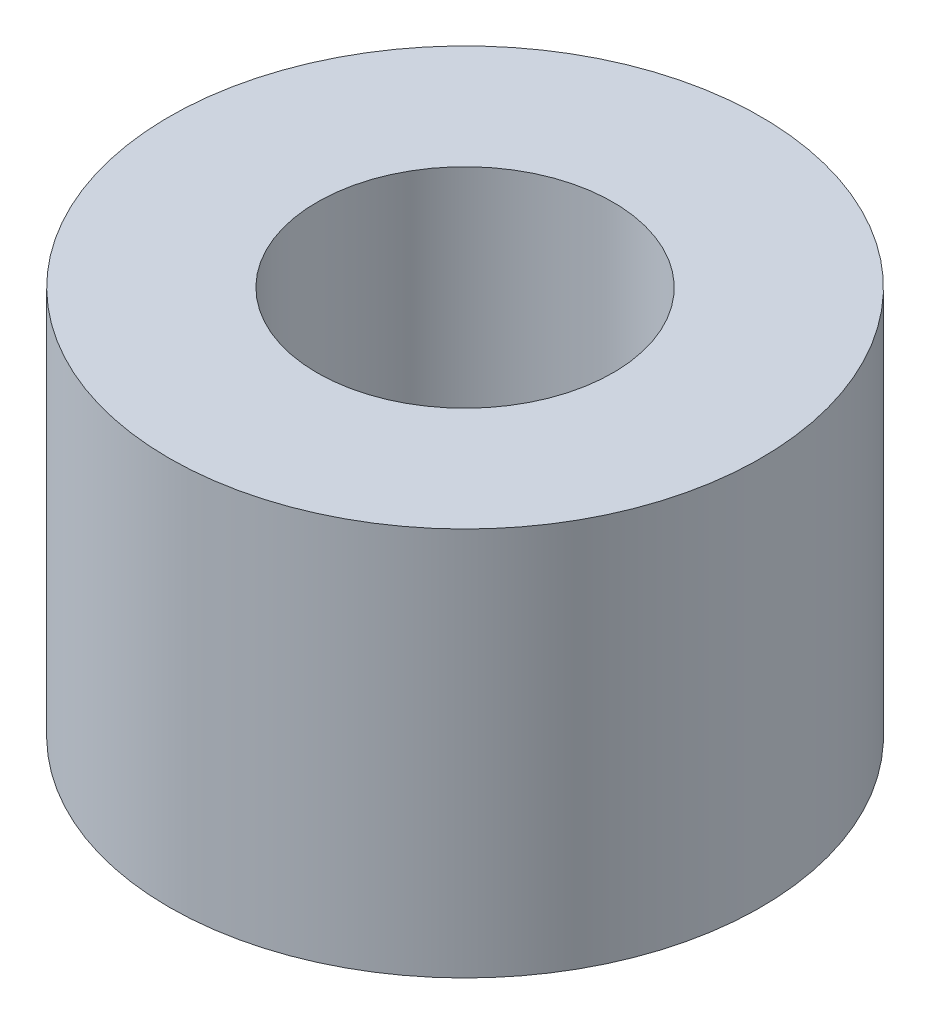
from build123d import *

# Parameters (mm, degrees)
SKETCH1_R           = 3.5
SKETCH1_R_2         = 1.75
BOSS_EXTRUDE1_DEPTH = 4.6


with BuildPart() as part:
    # Sketch1 → Boss-Extrude1 (new body)
    with BuildSketch(Plane(origin=(0, 0, 0), x_dir=(1, 0, 0), z_dir=(0, 1, 0))):
        Circle(SKETCH1_R)
        Circle(SKETCH1_R_2, mode=Mode.SUBTRACT)
    extrude(amount=BOSS_EXTRUDE1_DEPTH)


solid = part.part
